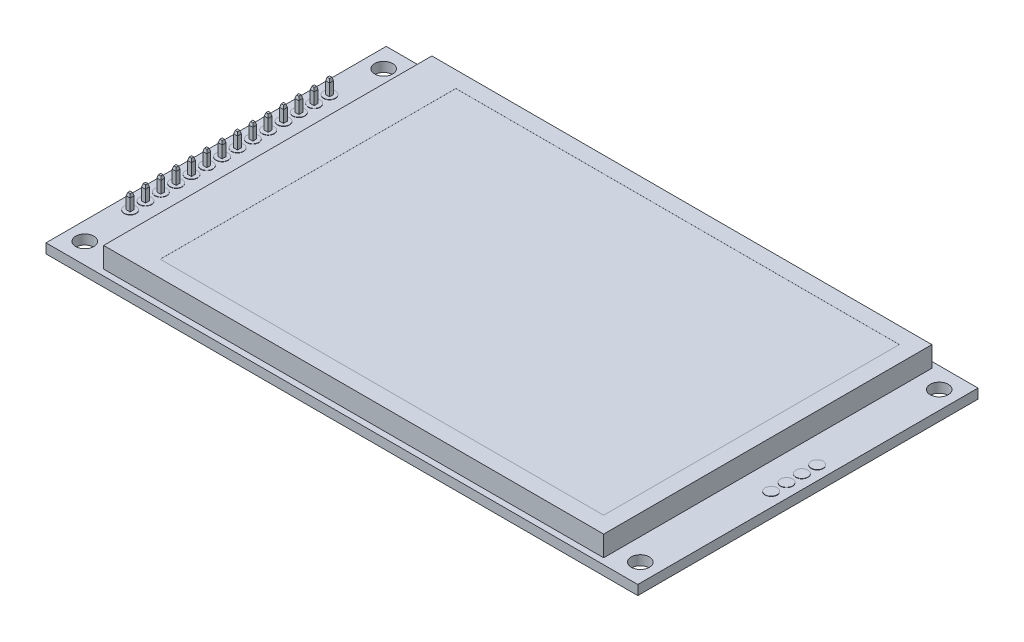
from build123d import *

# Parameters (mm, degrees)
SKETCH1_W                = 98
SKETCH1_H                = 56.34
BOSS_EXTRUDE1_DEPTH      = 1.6
SKETCH2_R                = 1.5
CUT_EXTRUDE1_DEPTH       = 1.6
SKETCH3_R                = 1
BOSS_EXTRUDE2_DEPTH      = 0.05
SKETCH4_W                = 2.54
SKETCH4_H                = 35.6
BOSS_EXTRUDE3_DEPTH      = 2.54
SKETCH5_R                = 1
BOSS_EXTRUDE4_DEPTH      = 0.05
BOSS_EXTRUDE4_DEPTH_BACK = 1.65
BOSS_EXTRUDE5_START      = -9.5
SKETCH6_W                = 0.65
SKETCH6_H                = 0.65
BOSS_EXTRUDE5_DEPTH      = 11.54
SKETCH7_W                = 0.65
SKETCH7_H                = 0.65
BOSS_EXTRUDE6_DEPTH      = 0.5
BOSS_EXTRUDE6_TAPER      = 15
SKETCH8_W                = 0.65
SKETCH8_H                = 0.65
BOSS_EXTRUDE7_DEPTH      = 0.5
BOSS_EXTRUDE7_TAPER      = 15
LPATTERN1_COUNT          = 14
LPATTERN1_PITCH          = 2.54
SKETCH9_W                = 82.8
SKETCH9_H                = 54.35
BOSS_EXTRUDE8_DEPTH      = 2.3
SKETCH10_W               = 82.8
SKETCH10_H               = 54.35
BOSS_EXTRUDE9_DEPTH      = 1.1
SKETCH11_W               = 73.44
SKETCH11_H               = 48.96
CUT_EXTRUDE2_DEPTH       = 0.01
SKETCH12_W               = 26.6
SKETCH12_H               = 16.7
BOSS_EXTRUDE10_DEPTH     = 2.9
CUT_EXTRUDE3_DEPTH       = 2.9


with BuildPart() as part:
    # Sketch1 → Boss-Extrude1 (new body)
    with BuildSketch(Plane(origin=(0, 0, 0), x_dir=(1, 0, 0), z_dir=(0, 1, 0))):
        Rectangle(SKETCH1_W, SKETCH1_H)
    extrude(amount=BOSS_EXTRUDE1_DEPTH)

    # Sketch2 → Cut-Extrude1 (cut)
    with BuildSketch(Plane(origin=(0, 1.6, 0), x_dir=(1, 0, 0), z_dir=(0, 1, 0))):
        with Locations((-46, 24.75)):
            Circle(SKETCH2_R)
        with Locations((46, 24.75)):
            Circle(SKETCH2_R)
        with Locations((46, -24.75)):
            Circle(SKETCH2_R)
        with Locations((-46, -24.75)):
            Circle(SKETCH2_R)
    extrude(amount=-CUT_EXTRUDE1_DEPTH, mode=Mode.SUBTRACT)

    # Sketch3 → Boss-Extrude2 (add)
    with BuildSketch(Plane(origin=(0, 1.6, 0), x_dir=(1, 0, 0), z_dir=(0, 1, 0))):
        with Locations((-46.73, -16.51)):
            Circle(SKETCH3_R)
        with Locations((-46.73, -13.97)):
            Circle(SKETCH3_R)
        with Locations((-46.73, -11.43)):
            Circle(SKETCH3_R)
        with Locations((-46.73, -8.89)):
            Circle(SKETCH3_R)
        with Locations((-46.73, -6.35)):
            Circle(SKETCH3_R)
        with Locations((-46.73, -3.81)):
            Circle(SKETCH3_R)
        with Locations((-46.73, -1.27)):
            Circle(SKETCH3_R)
        with Locations((-46.73, 1.27)):
            Circle(SKETCH3_R)
        with Locations((-46.73, 3.81)):
            Circle(SKETCH3_R)
        with Locations((-46.73, 6.35)):
            Circle(SKETCH3_R)
        with Locations((-46.73, 8.89)):
            Circle(SKETCH3_R)
        with Locations((-46.73, 11.43)):
            Circle(SKETCH3_R)
        with Locations((-46.73, 13.97)):
            Circle(SKETCH3_R)
        with Locations((-46.73, 16.51)):
            Circle(SKETCH3_R)
    extrude(amount=BOSS_EXTRUDE2_DEPTH)

    # Sketch4 → Boss-Extrude3 (add)
    with BuildSketch(Plane.XZ):
        with Locations((-46.73, 0)):
            Rectangle(SKETCH4_W, SKETCH4_H)
    extrude(amount=BOSS_EXTRUDE3_DEPTH)

    # Sketch5 → Boss-Extrude4 (add, two sides)
    with BuildSketch(Plane(origin=(0, 1.6, 0), x_dir=(1, 0, 0), z_dir=(0, 1, 0))) as boss_extrude4_sk:
        with Locations((46.73, -3.81)):
            Circle(SKETCH5_R)
        with Locations((46.73, -1.27)):
            Circle(SKETCH5_R)
        with Locations((46.73, 1.27)):
            Circle(SKETCH5_R)
        with Locations((46.73, 3.81)):
            Circle(SKETCH5_R)
    extrude(amount=BOSS_EXTRUDE4_DEPTH)
    extrude(boss_extrude4_sk.sketch, amount=-BOSS_EXTRUDE4_DEPTH_BACK)

    # Sketch6 → Boss-Extrude5 (add)
    with BuildSketch(Plane(origin=(0, 1.6, 0), x_dir=(1, 0, 0), z_dir=(0, 1, 0)).offset(BOSS_EXTRUDE5_START)):
        with Locations((-46.73, -16.51)):
            Rectangle(SKETCH6_W, SKETCH6_H)
    boss_extrude5 = extrude(amount=BOSS_EXTRUDE5_DEPTH)

    # Sketch7 → Boss-Extrude6 (add)
    with BuildSketch(Plane(origin=(0, 3.64, 0), x_dir=(1, 0, 0), z_dir=(0, 1, 0))):
        with Locations((-46.73, -16.51)):
            Rectangle(SKETCH7_W, SKETCH7_H)
    boss_extrude6 = extrude(amount=BOSS_EXTRUDE6_DEPTH, taper=BOSS_EXTRUDE6_TAPER)

    # Sketch8 → Boss-Extrude7 (add)
    with BuildSketch(Plane.XZ.offset(7.9)):
        with Locations((-46.73, 16.51)):
            Rectangle(SKETCH8_W, SKETCH8_H)
    boss_extrude7 = extrude(amount=BOSS_EXTRUDE7_DEPTH, taper=BOSS_EXTRUDE7_TAPER)

    # LPattern1: Boss-Extrude5, Boss-Extrude6, Boss-Extrude7 ×14
    with Locations(*[(0, 0, -i * LPATTERN1_PITCH) for i in range(1, LPATTERN1_COUNT)]):
        add(boss_extrude5)
        add(boss_extrude6)
        add(boss_extrude7)

    # Sketch9 → Boss-Extrude8 (add)
    with BuildSketch(Plane(origin=(0, 1.6, 0), x_dir=(1, 0, 0), z_dir=(0, 1, 0))):
        with Locations((0.95, 0.005)):
            Rectangle(SKETCH9_W, SKETCH9_H)
    extrude(amount=BOSS_EXTRUDE8_DEPTH)

    # Sketch10 → Boss-Extrude9 (add)
    with BuildSketch(Plane(origin=(0, 3.9, 0), x_dir=(1, 0, 0), z_dir=(0, 1, 0))):
        with Locations((0.95, 0.005)):
            Rectangle(SKETCH10_W, SKETCH10_H)
    extrude(amount=BOSS_EXTRUDE9_DEPTH)

    # Sketch11 → Cut-Extrude2 (cut)
    with BuildSketch(Plane(origin=(0, 5, 0), x_dir=(1, 0, 0), z_dir=(0, 1, 0))):
        with Locations((2.925, 0.015)):
            Rectangle(SKETCH11_W, SKETCH11_H)
    extrude(amount=-CUT_EXTRUDE2_DEPTH, mode=Mode.SUBTRACT)

    # Sketch12 → Boss-Extrude10 (add)
    with BuildSketch(Plane.XZ):
        with Locations((16.1, -17.52)):
            Rectangle(SKETCH12_W, SKETCH12_H)
    extrude(amount=BOSS_EXTRUDE10_DEPTH)

    # Sketch13 → Cut-Extrude3 (cut)
    with BuildSketch(Plane.XZ.offset(2.9)):
        Polygon((27.4, -9.17), (27.4, -14.17), (29.4, -16.97), (29.4, -9.17), align=None)
    extrude(amount=-CUT_EXTRUDE3_DEPTH, mode=Mode.SUBTRACT)


solid = part.part
